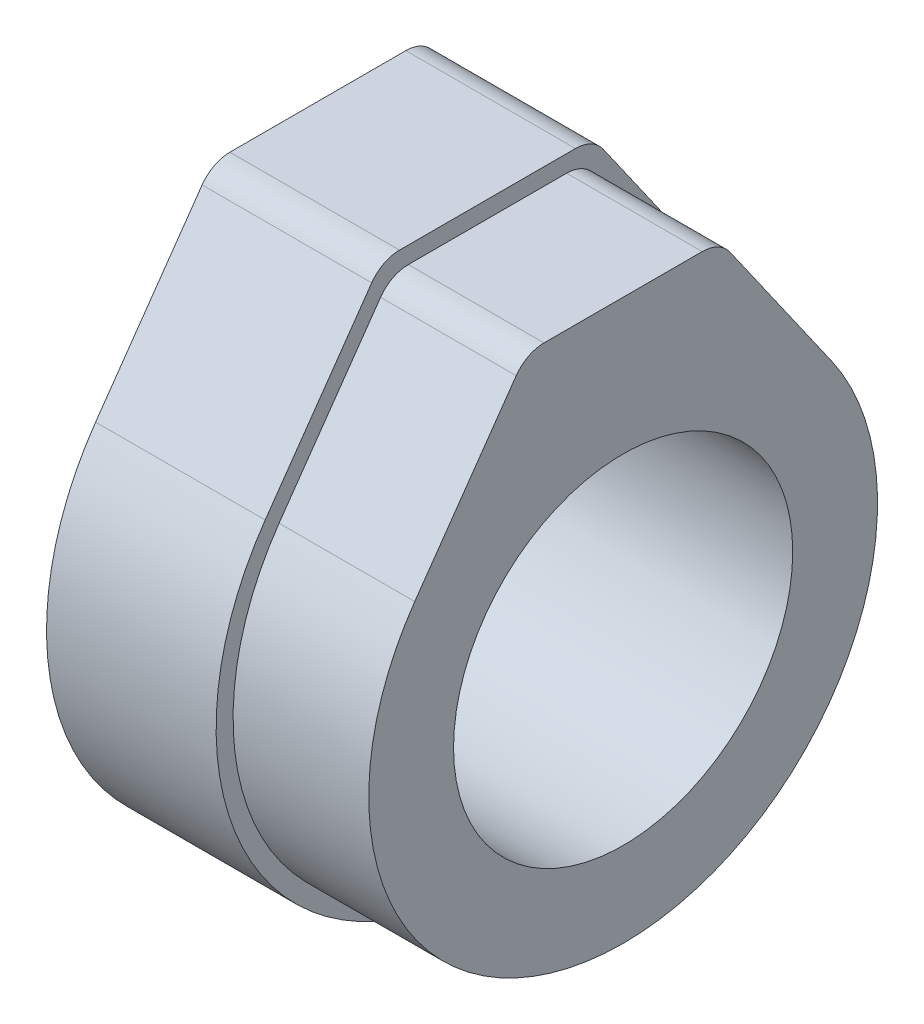
from build123d import *

# Parameters (mm, degrees)
AUFSATZ_LINEAR_AUSTRAGEN1_DEPTH = 10
AUFSATZ_LINEAR_AUSTRAGEN2_DEPTH = 8
VERRUNDUNG1_R                   = 2
SCHNITT_LINEAR_AUSTRAGEN1_REACH = 20
SKIZZE3_R                       = 10


with BuildPart() as part:
    # Skizze1 → Aufsatz-Linear austragen1 (new body)
    with BuildSketch(Plane(origin=(0, 0, 0), x_dir=(0, 0, -1), z_dir=(1, 0, 0))):
        with BuildLine():
            Line((-6.228450194, 19), (-13.106432709, 9.177222982))
            ThreePointArc((-13.106432709, 9.177222982), (0, -16), (13.106432709, 9.177222982))
            Line((13.106432709, 9.177222982), (6.228450194, 19))
            Line((6.228450194, 19), (-6.228450194, 19))
        make_face()
    extrude(amount=AUFSATZ_LINEAR_AUSTRAGEN1_DEPTH)

    # Skizze2 → Aufsatz-Linear austragen2 (add)
    with BuildSketch(Plane(origin=(10, 0, 0), x_dir=(0, 0, -1), z_dir=(1, 0, 0))):
        with BuildLine():
            Line((-12.287280664, 8.603646545), (-5.707883144, 18))
            Line((-5.707883144, 18), (5.707883144, 18))
            Line((5.707883144, 18), (12.287280664, 8.603646545))
            ThreePointArc((12.287280664, 8.603646545), (0, -15), (-12.287280664, 8.603646545))
        make_face()
    extrude(amount=AUFSATZ_LINEAR_AUSTRAGEN2_DEPTH)

    # Verrundung1
    verrundung1_edges = [part.edges().sort_by_distance(p)[0] for p in [
        (14, 18, -5.707883144),
        (14, 18, 5.707883144),
        (5, 19, -6.228450194),
        (5, 19, 6.228450194),
    ]]
    fillet(verrundung1_edges, radius=VERRUNDUNG1_R)

    # Skizze3 → Schnitt-Linear austragen1 (cut, up to next)
    with BuildSketch(Plane(origin=(18, 0, 0), x_dir=(0, 0, -1), z_dir=(1, 0, 0)), mode=Mode.PRIVATE) as schnitt_linear_austragen1_sk1:
        Circle(SKIZZE3_R)
    schnitt_linear_austragen1_tool1 = extrude(schnitt_linear_austragen1_sk1.sketch, amount=-SCHNITT_LINEAR_AUSTRAGEN1_REACH, mode=Mode.PRIVATE) & part.part
    add(schnitt_linear_austragen1_tool1.solids().sort_by_distance((18, 0, 0))[0], mode=Mode.SUBTRACT)


solid = part.part
